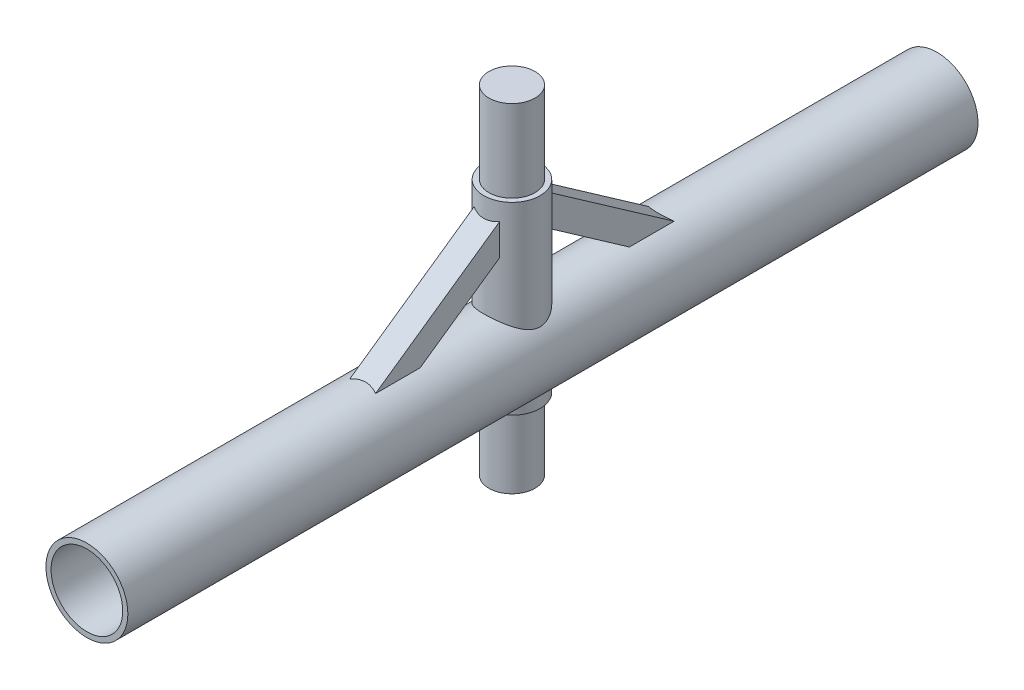
from build123d import *

# Parameters (mm, degrees)
SKETCH1_R                = 40
SKETCH1_R_2              = 35
EXTRUDE_THIN1_DEPTH      = 415
SKETCH2_R                = 27.5
SKETCH2_R_2              = 22.5
EXTRUDE_THIN3_DEPTH      = 140
EXTRUDE_THIN3_DEPTH_BACK = 40
SKETCH3_R                = 22.5
BOSS_EXTRUDE1_DEPTH      = 80
BOSS_EXTRUDE1_DEPTH_BACK = 250
EXTRUDE_THIN4_DEPTH      = 12.5
SKETCH6_R                = 35
CUT_EXTRUDE1_DEPTH       = 831.0000001


with BuildPart() as part:
    # Sketch1 → Extrude-Thin1 (new body, symmetric)
    with BuildSketch(Plane.XY):
        Circle(SKETCH1_R)
        Circle(SKETCH1_R_2, mode=Mode.SUBTRACT)
    extrude(amount=EXTRUDE_THIN1_DEPTH, both=True)

    # Sketch2 → Extrude-Thin3 (add, two sides)
    with BuildSketch(Plane(origin=(0, 0, 0), x_dir=(1, 0, 0), z_dir=(0, 1, 0))) as extrude_thin3_sk:
        Circle(SKETCH2_R)
        Circle(SKETCH2_R_2, mode=Mode.SUBTRACT)
    extrude(amount=EXTRUDE_THIN3_DEPTH)
    extrude(extrude_thin3_sk.sketch, amount=-EXTRUDE_THIN3_DEPTH_BACK)

    # Sketch3 → Boss-Extrude1 (add, two sides)
    with BuildSketch(Plane(origin=(0, 140, 0), x_dir=(1, 0, 0), z_dir=(0, 1, 0))) as boss_extrude1_sk:
        Circle(SKETCH3_R)
    extrude(amount=BOSS_EXTRUDE1_DEPTH)
    extrude(boss_extrude1_sk.sketch, amount=-BOSS_EXTRUDE1_DEPTH_BACK)


with BuildPart() as body_2:
    # Sketch4 → Extrude-Thin4 (new body, symmetric)
    with BuildSketch(Plane(origin=(0, 0, 0), x_dir=(0, 0, -1), z_dir=(1, 0, 0))):
        Polygon((0, 140), (-200, 0), (-185.663441391, -20.480798013), (14.336558609, 119.519201987), align=None)
    extrude(amount=EXTRUDE_THIN4_DEPTH, both=True)


with BuildPart() as body_3:
    # Mirror2: mirrored copy
    add(body_2.part.mirror(Plane.XY))


with BuildPart() as cut_extrude1_tool:
    # Sketch6 → Cut-Extrude1 (new body, through all)
    with BuildSketch(Plane.XY.offset(415)):
        Circle(SKETCH6_R)
    extrude(amount=-CUT_EXTRUDE1_DEPTH)


with BuildPart() as part_1:
    add(part.part)

    # Cut-Extrude1: cut by cut_extrude1_tool
    add(cut_extrude1_tool.part, mode=Mode.SUBTRACT)


with BuildPart() as body_2_1:
    add(body_2.part)

    # Cut-Extrude1: cut by cut_extrude1_tool
    add(cut_extrude1_tool.part, mode=Mode.SUBTRACT)


with BuildPart() as body_3_1:
    add(body_3.part)

    # Cut-Extrude1: cut by cut_extrude1_tool
    add(cut_extrude1_tool.part, mode=Mode.SUBTRACT)


solid = Compound([part_1.part, body_2_1.part, body_3_1.part])
